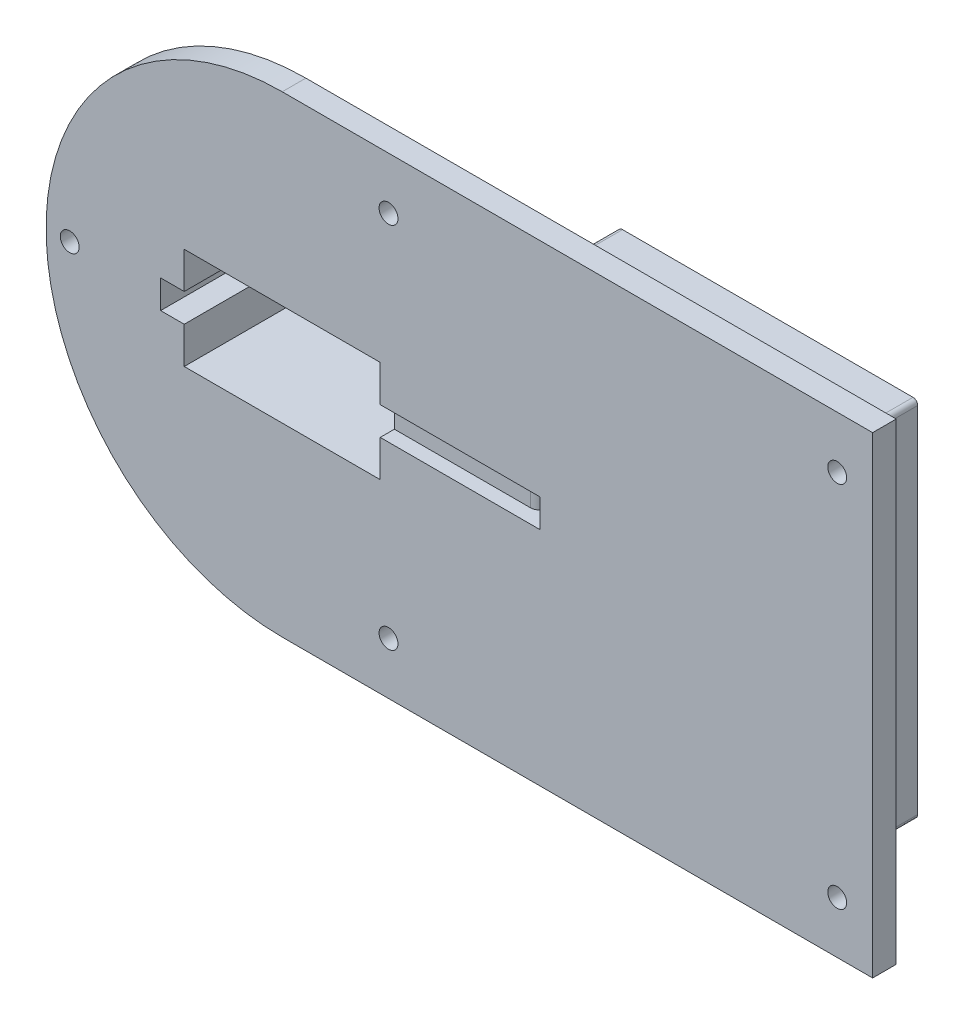
from build123d import *

# Parameters (mm, degrees)
SKETCH1_W           = 60
SKETCH1_H           = 30
SKETCH1_W_2         = 41.5
SKETCH1_H_2         = 21.5
BOSS_EXTRUDE1_DEPTH = 27
SKETCH2_R           = 50
BOSS_EXTRUDE2_DEPTH = 5
FILLET2_R           = 10
SKETCH6_R           = 1
CUT_EXTRUDE2_DEPTH  = 15
SKETCH7_W           = 41.5
SKETCH7_H           = 21.5
CUT_EXTRUDE3_DEPTH  = 69
SKETCH8_W           = 10
SKETCH8_H           = 6
CUT_EXTRUDE4_DEPTH  = 75
SKETCH10_W          = 74.59493419
SKETCH10_H          = 6
CUT_EXTRUDE5_DEPTH  = 3
SKETCH11_R          = 2
CUT_EXTRUDE6_DEPTH  = 16
BOSS_EXTRUDE3_DEPTH = 5
SKETCH13_R          = 2.5
SKETCH13_R_2        = 1
BOSS_EXTRUDE4_DEPTH = 4
SKETCH14_R          = 2.5
SKETCH14_R_2        = 1
BOSS_EXTRUDE5_DEPTH = 4
SKETCH15_R          = 2.5
SKETCH15_R_2        = 1
BOSS_EXTRUDE6_DEPTH = 4
BOSS_EXTRUDE8_DEPTH = 17.5
SKETCH17_W          = 3
SKETCH17_H          = 6
CUT_EXTRUDE7_DEPTH  = 17.5
SKETCH18_W          = 1.640081146
SKETCH18_H          = 6
CUT_EXTRUDE8_DEPTH  = 3
SKETCH20_W          = 13
SKETCH20_H          = 15.827650688
CUT_EXTRUDE9_DEPTH  = 25
SKETCH21_W          = 10
SKETCH21_H          = 3
CUT_EXTRUDE10_DEPTH = 13.5
SKETCH23_W          = 13
SKETCH23_H          = 3
SKETCH23_W_2        = 10
BOSS_EXTRUDE9_DEPTH = 1.75
FILLET3_R           = 1
SKETCH24_R          = 2
CUT_EXTRUDE11_DEPTH = 17
SKETCH25_W          = 10.72256849
SKETCH25_H          = 6
CUT_EXTRUDE12_DEPTH = 3
FILLET4_R           = 2


with BuildPart() as part:
    # Sketch1 → Boss-Extrude1 (new body)
    with BuildSketch(Plane.XY):
        Rectangle(SKETCH1_W, SKETCH1_H)
        Rectangle(SKETCH1_W_2, SKETCH1_H_2, mode=Mode.SUBTRACT)
    extrude(amount=BOSS_EXTRUDE1_DEPTH)

    # Sketch2 → Boss-Extrude2 (add)
    with BuildSketch(Plane.XY.offset(27)):
        Circle(SKETCH2_R)
    extrude(amount=BOSS_EXTRUDE2_DEPTH)

    # Fillet2
    fillet2_edges = [part.edges().sort_by_distance(p)[0] for p in [
        (30, 0, 27),
        (0, 15, 27),
        (-30, 0, 27),
        (0, -15, 27),
    ]]
    fillet(fillet2_edges, radius=FILLET2_R)

    # Sketch6 → Cut-Extrude2 (cut)
    with BuildSketch(Plane(origin=(0, 0, 0), x_dir=(-1, 0, 0), z_dir=(0, 0, -1))):
        with Locations((24.4, 5)):
            Circle(SKETCH6_R)
        with Locations((-24.4, 5)):
            Circle(SKETCH6_R)
        with Locations((24.4, -5)):
            Circle(SKETCH6_R)
        with Locations((-24.4, -5)):
            Circle(SKETCH6_R)
    extrude(amount=-CUT_EXTRUDE2_DEPTH, mode=Mode.SUBTRACT)

    # Sketch7 → Cut-Extrude3 (cut)
    with BuildSketch(Plane(origin=(0, 0, 0), x_dir=(-1, 0, 0), z_dir=(0, 0, -1))):
        Rectangle(SKETCH7_W, SKETCH7_H)
    extrude(amount=-CUT_EXTRUDE3_DEPTH, mode=Mode.SUBTRACT)

    # Sketch8 → Cut-Extrude4 (cut)
    with BuildSketch(Plane(origin=(0, 0, 0), x_dir=(-1, 0, 0), z_dir=(0, 0, -1))):
        with Locations((20.75, 0)):
            Rectangle(SKETCH8_W, SKETCH8_H)
    extrude(amount=-CUT_EXTRUDE4_DEPTH, mode=Mode.SUBTRACT)

    # Sketch10 → Cut-Extrude5 (cut)
    with BuildSketch(Plane.XY.offset(32)):
        with Locations((37.297467095, 0)):
            Rectangle(SKETCH10_W, SKETCH10_H)
    extrude(amount=-CUT_EXTRUDE5_DEPTH, mode=Mode.SUBTRACT)

    # Sketch11 → Cut-Extrude6 (cut)
    with BuildSketch(Plane(origin=(0, 0, 27), x_dir=(-1, 0, 0), z_dir=(0, 0, -1))):
        with Locations((45, 0)):
            Circle(SKETCH11_R)
        with Locations((-22.5, 38.97114317)):
            Circle(SKETCH11_R)
        with Locations((-22.5, -38.97114317)):
            Circle(SKETCH11_R)
    extrude(amount=-CUT_EXTRUDE6_DEPTH, mode=Mode.SUBTRACT)

    # Sketch12 → Boss-Extrude3 (add)
    with BuildSketch(Plane(origin=(0, 0, 27), x_dir=(-1, 0, 0), z_dir=(0, 0, -1))):
        with BuildLine():
            Line((0, -50), (-125, -50))
            Line((-125, -50), (-125, 50))
            Line((-125, 50), (0, 50))
            ThreePointArc((0, 50), (-50, 0), (0, -50))
        make_face()
    extrude(amount=-BOSS_EXTRUDE3_DEPTH)

    # Sketch13 → Boss-Extrude4 (add)
    with BuildSketch(Plane(origin=(0, 0, 27), x_dir=(-1, 0, 0), z_dir=(0, 0, -1))):
        with Locations((-104.5, -20)):
            Circle(SKETCH13_R)
        with Locations((-104.5, -20)):
            Circle(SKETCH13_R_2, mode=Mode.SUBTRACT)
    extrude(amount=BOSS_EXTRUDE4_DEPTH)

    # Sketch14 → Boss-Extrude5 (add)
    with BuildSketch(Plane(origin=(0, 0, 27), x_dir=(-1, 0, 0), z_dir=(0, 0, -1))):
        with Locations((-56.25, -21.25)):
            Circle(SKETCH14_R)
        with Locations((-56.25, -21.25)):
            Circle(SKETCH14_R_2, mode=Mode.SUBTRACT)
    extrude(amount=BOSS_EXTRUDE5_DEPTH)

    # Sketch15 → Boss-Extrude6 (add)
    with BuildSketch(Plane(origin=(0, 0, 27), x_dir=(-1, 0, 0), z_dir=(0, 0, -1))):
        with Locations((-61.34, 30.85)):
            Circle(SKETCH15_R)
        with Locations((-61.34, 30.85)):
            Circle(SKETCH15_R_2, mode=Mode.SUBTRACT)
        with Locations((-89.2, 30.85)):
            Circle(SKETCH15_R)
        with Locations((-89.2, 30.85)):
            Circle(SKETCH15_R_2, mode=Mode.SUBTRACT)
    extrude(amount=BOSS_EXTRUDE6_DEPTH)

    # Sketch16 → Boss-Extrude8 (add)
    with BuildSketch(Plane(origin=(0, 0, 27), x_dir=(-1, 0, 0), z_dir=(0, 0, -1))):
        Polygon((-112.05, 38.25), (-48.55, 38.25), (-48.55, -38.75), (-112.05, -38.75), (-112.05, 7.205124567), align=None)
        Polygon((-109.05, 7.205124567), (-109.05, 35.25), (-51.55, 35.25), (-51.55, -35.75), (-109.05, -35.75), align=None, mode=Mode.SUBTRACT)
    extrude(amount=BOSS_EXTRUDE8_DEPTH)

    # Sketch17 → Cut-Extrude7 (cut)
    with BuildSketch(Plane(origin=(0, 0, 27), x_dir=(-1, 0, 0), z_dir=(0, 0, -1))):
        with Locations((-53.05, 0)):
            Rectangle(SKETCH17_W, SKETCH17_H)
    extrude(amount=-CUT_EXTRUDE7_DEPTH, mode=Mode.SUBTRACT)

    # Sketch18 → Cut-Extrude8 (cut)
    with BuildSketch(Plane.XY.offset(32)):
        with Locations((50.729959427, 0)):
            Rectangle(SKETCH18_W, SKETCH18_H)
    extrude(amount=-CUT_EXTRUDE8_DEPTH, mode=Mode.SUBTRACT)

    # Sketch20 → Cut-Extrude9 (cut)
    with BuildSketch(Plane(origin=(0, 0, 23), x_dir=(-1, 0, 0), z_dir=(0, 0, -1))):
        with Locations((-91.75, -35.907506038)):
            Rectangle(SKETCH20_W, SKETCH20_H)
    extrude(amount=CUT_EXTRUDE9_DEPTH, mode=Mode.SUBTRACT)

    # Sketch21 → Cut-Extrude10 (cut)
    with BuildSketch(Plane(origin=(0, 0, 9.5), x_dir=(-1, 0, 0), z_dir=(0, 0, -1))):
        with Locations((-61.43, -37.25)):
            Rectangle(SKETCH21_W, SKETCH21_H)
    extrude(amount=-CUT_EXTRUDE10_DEPTH, mode=Mode.SUBTRACT)

    # Sketch23 → Boss-Extrude9 (add)
    with BuildSketch(Plane(origin=(0, 0, 23), x_dir=(-1, 0, 0), z_dir=(0, 0, -1))):
        with Locations((-91.75, -37.25)):
            Rectangle(SKETCH23_W, SKETCH23_H)
        with Locations((-61.43, -37.25)):
            Rectangle(SKETCH23_W_2, SKETCH23_H)
    extrude(amount=BOSS_EXTRUDE9_DEPTH)

    # Fillet3
    fillet3_edges = [part.edges().sort_by_distance(p)[0] for p in [
        (112.05, 38.25, 18.25),
        (112.05, -38.75, 18.25),
        (48.55, -38.75, 18.25),
        (48.55, 38.25, 18.25),
    ]]
    fillet(fillet3_edges, radius=FILLET3_R)

    # Sketch24 → Cut-Extrude11 (cut)
    with BuildSketch(Plane(origin=(0, 0, 27), x_dir=(-1, 0, 0), z_dir=(0, 0, -1))):
        with Locations((-117.5, 38.97114317)):
            Circle(SKETCH24_R)
        with Locations((-117.5, -38.97114317)):
            Circle(SKETCH24_R)
    extrude(amount=-CUT_EXTRUDE11_DEPTH, mode=Mode.SUBTRACT)

    # Sketch25 → Cut-Extrude12 (cut)
    with BuildSketch(Plane(origin=(0, 0, 0), x_dir=(-1, 0, 0), z_dir=(0, 0, -1))):
        with Locations((25.75, 0)):
            Rectangle(SKETCH25_W, SKETCH25_H)
    extrude(amount=-CUT_EXTRUDE12_DEPTH, mode=Mode.SUBTRACT)

    # Fillet4
    fillet4_edges = [part.edges().sort_by_distance(p)[0] for p in [
        (-25.75, 0, 3),
        (51.55, 0, 29),
    ]]
    fillet(fillet4_edges, radius=FILLET4_R)


solid = part.part
